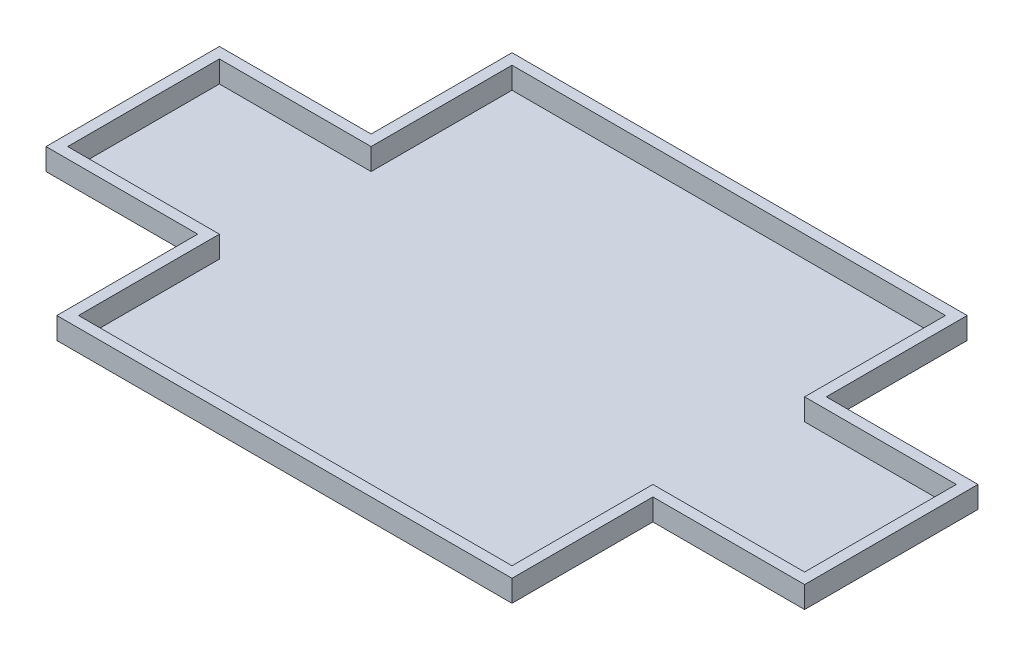
from build123d import *

# Parameters (mm, degrees)
SALIENTE_EXTRUIR1_DEPTH = 20
SALIENTE_EXTRUIR2_DEPTH = 100


with BuildPart() as part:
    # Croquis1 → Saliente-Extruir1 (new body)
    with BuildSketch(Plane(origin=(0, 0, 0), x_dir=(1, 0, 0), z_dir=(0, 1, 0))):
        Polygon((0, 1350), (0, 2000), (2000, 2000), (2000, 1350), (2700, 1350), (2700, 650), (2000, 650), (2000, 0), (0, 0), (0, 650), (-700, 650), (-700, 1350), align=None)
    extrude(amount=SALIENTE_EXTRUIR1_DEPTH)


with BuildPart() as body_2:
    # Croquis2 → Saliente-Extruir2 (new body)
    with BuildSketch(Plane(origin=(0, 20, 0), x_dir=(1, 0, 0), z_dir=(0, 1, 0))):
        Polygon((-750, 600), (-750, 1400), (-50, 1400), (-50, 2050), (2050, 2050), (2050, 1400), (2750, 1400), (2750, 600), (2050, 600), (2050, -50), (-50, -50), (-50, 600), align=None)
        Polygon((-700, 1350), (0, 1350), (0, 2000), (2000, 2000), (2000, 1350), (2700, 1350), (2700, 650), (2000, 650), (2000, 0), (0, 0), (0, 650), (-700, 650), align=None, mode=Mode.SUBTRACT)
    extrude(amount=SALIENTE_EXTRUIR2_DEPTH)


solid = Compound([part.part, body_2.part])
